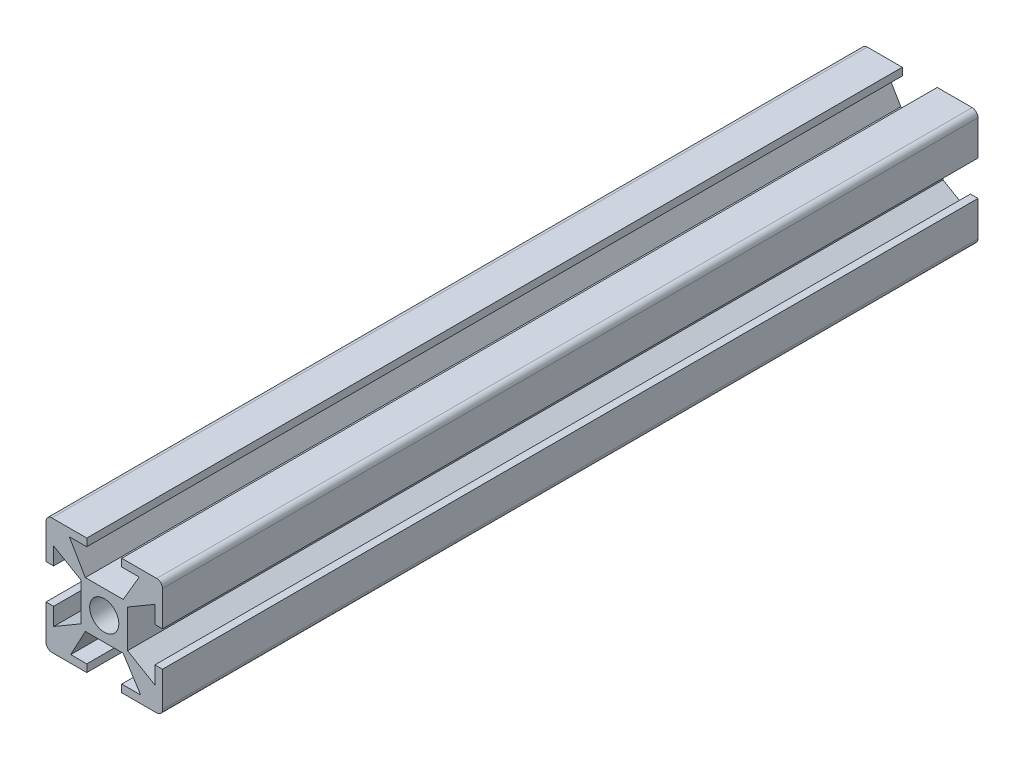
from build123d import *

# Parameters (mm, degrees)
CROQUIS1_W              = 8
CROQUIS1_H              = 8
CROQUIS1_R              = 2.5
SALIENTE_EXTRUIR4_DEPTH = 140


with BuildPart() as part:
    # Croquis1 → Saliente-Extruir4 (new body)
    with BuildSketch(Plane.XY):
        with BuildLine():
            Line((-3, 8.7), (-3, 10))
            Line((-3, 10), (-9, 10))
            ThreePointArc((-9, 10), (-9.707106781, 9.707106781), (-10, 9))
            Line((-10, 9), (-10, 3))
            Line((-10, 3), (-8.7, 3))
            Line((-8.7, 3), (-8.7, 6))
            Line((-8.7, 6), (-4, 3.25))
            Line((-4, 3.25), (-4, 4))
            Line((-4, 4), (-3.25, 4))
            Line((-3.25, 4), (-6, 8.7))
            Line((-6, 8.7), (-3, 8.7))
        make_face()
        with BuildLine():
            Line((9, 10), (3, 10))
            Line((3, 10), (3, 8.7))
            Line((3, 8.7), (6, 8.7))
            Line((6, 8.7), (3.25, 4))
            Line((3.25, 4), (4, 4))
            Line((4, 4), (4, 3.25))
            Line((4, 3.25), (8.7, 6))
            Line((8.7, 6), (8.7, 3))
            Line((8.7, 3), (10, 3))
            Line((10, 3), (10, 9))
            ThreePointArc((10, 9), (9.707106781, 9.707106781), (9, 10))
        make_face()
        with BuildLine():
            Line((10, -9), (10, -3))
            Line((10, -3), (8.7, -3))
            Line((8.7, -3), (8.7, -6))
            Line((8.7, -6), (4, -3.25))
            Line((4, -3.25), (4, -4))
            Line((4, -4), (3.25, -4))
            Line((3.25, -4), (6.25, -8.7))
            Line((6.25, -8.7), (3, -8.7))
            Line((3, -8.7), (3, -10))
            Line((3, -10), (9, -10))
            ThreePointArc((9, -10), (9.707106781, -9.707106781), (10, -9))
        make_face()
        with BuildLine():
            Line((-8.7, -3), (-10, -3))
            Line((-10, -3), (-10, -9))
            ThreePointArc((-10, -9), (-9.707106781, -9.707106781), (-9, -10))
            Line((-9, -10), (-3, -10))
            Line((-3, -10), (-3, -8.7))
            Line((-3, -8.7), (-5.75, -8.7))
            Line((-5.75, -8.7), (-3.25, -4))
            Line((-3.25, -4), (-4, -4))
            Line((-4, -4), (-4, -3.25))
            Line((-4, -3.25), (-8.7, -6))
            Line((-8.7, -6), (-8.7, -3))
        make_face()
        Rectangle(CROQUIS1_W, CROQUIS1_H)
        Circle(CROQUIS1_R, mode=Mode.SUBTRACT)
    extrude(amount=SALIENTE_EXTRUIR4_DEPTH)


solid = part.part
